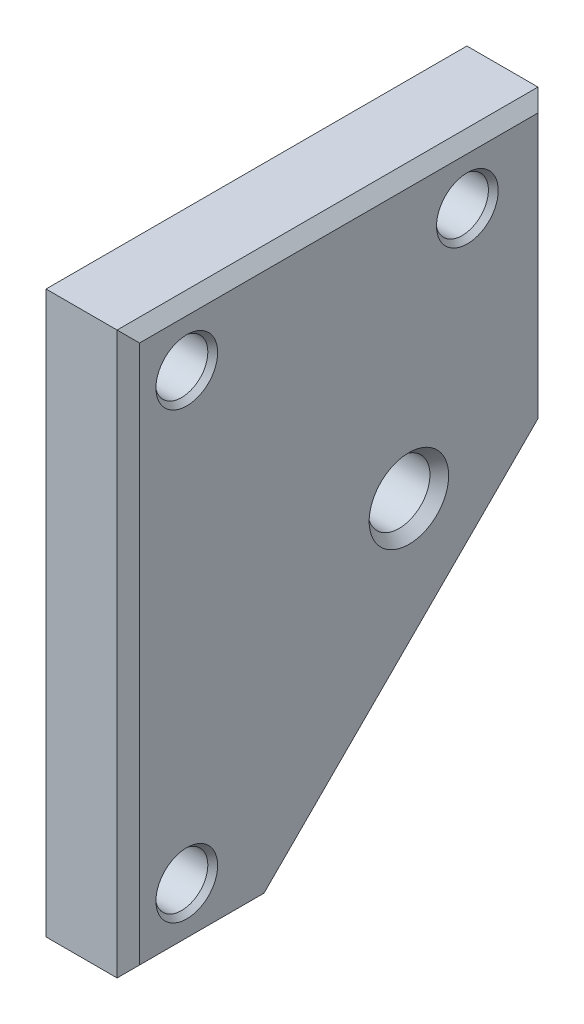
from build123d import *

# Parameters (mm, degrees)
SKETCH1_W                        = 57.15
SKETCH1_H                        = 76.2
EXTRUDE1_DEPTH                   = 12.7
F_1_4_CLEARANCE_HOLE1_AT_2_COUNT = 2
F_1_4_CLEARANCE_HOLE1_AT_2_PITCH = 60.325
F_1_4_CLEARANCE_HOLE1_AT_3_COUNT = 2
F_1_4_CLEARANCE_HOLE1_AT_3_PITCH = 38.1
CUT_EXTRUDE2_DEPTH               = 13.7
CHAMFER1_SIZE                    = 1.524


with BuildPart() as part:
    # Sketch1 → Extrude1 (new body)
    with BuildSketch(Plane(origin=(0, 0, 0), x_dir=(0, 0, -1), z_dir=(1, 0, 0))):
        Rectangle(SKETCH1_W, SKETCH1_H)
    extrude(amount=EXTRUDE1_DEPTH)

    # Sketch2 → 1/4 Clearance Hole1 (revolve, cut)
    with BuildSketch(Plane(origin=(12.7, 30.1625, 20.6375), x_dir=(0, 0, -1), z_dir=(0, 1, 0))):
        Polygon((0, 0), (0, 12.7), (4.191, 12.7), (3.57124, 11.987047676), (3.57124, 0.712952324), (4.191, 0), align=None)
    f_1_4_clearance_hole1 = revolve(axis=Axis((19.05, 30.1625, 20.6375), (-1, 0, 0)), mode=Mode.SUBTRACT)

    # 1/4 Clearance Hole1 at 2: 1/4 Clearance Hole1 ×2
    with Locations(*[(0, -i * F_1_4_CLEARANCE_HOLE1_AT_2_PITCH, 0) for i in range(1, F_1_4_CLEARANCE_HOLE1_AT_2_COUNT)]):
        add(f_1_4_clearance_hole1, mode=Mode.SUBTRACT)

    # 1/4 Clearance Hole1 at 3: 1/4 Clearance Hole1 ×2
    with Locations(*[(0, 0, -i * F_1_4_CLEARANCE_HOLE1_AT_3_PITCH) for i in range(1, F_1_4_CLEARANCE_HOLE1_AT_3_COUNT)]):
        add(f_1_4_clearance_hole1, mode=Mode.SUBTRACT)

    # Sketch4 → 3/8-24 Tapped Hole1 (revolve, cut)
    with BuildSketch(Plane(origin=(12.7, 0, -9.525), x_dir=(0, 0, -1), z_dir=(0, 1, 0))):
        Polygon((0, 0), (0, 12.7), (5.3975, 12.7), (4.2164, 11.341299874), (4.2164, 1.358700126), (5.3975, 0), align=None)
    revolve(axis=Axis((19.05, 0, -9.525), (-1, 0, 0)), mode=Mode.SUBTRACT)

    # Sketch7 → Cut-Extrude2 (cut, through all)
    with BuildSketch(Plane(origin=(12.7, 0, 0), x_dir=(0, 0, -1), z_dir=(1, 0, 0))):
        Polygon((-9.525, -38.1), (28.575, 0), (28.575, -38.1), align=None)
    extrude(amount=-CUT_EXTRUDE2_DEPTH, mode=Mode.SUBTRACT)

    # Chamfer1
    chamfer1_edges = [part.edges().sort_by_distance(p)[0] for p in [
        (12.7, 38.1, 0),
        (12.7, 0, 28.575),
        (0, 38.1, 0),
        (0, 19.05, -28.575),
        (12.7, 19.05, -28.575),
        (0, -19.05, -9.525),
        (12.7, -19.05, -9.525),
        (0, -38.1, 19.05),
        (0, 0, 28.575),
        (12.7, -38.1, 19.05),
    ]]
    chamfer(chamfer1_edges, length=CHAMFER1_SIZE)


solid = part.part
